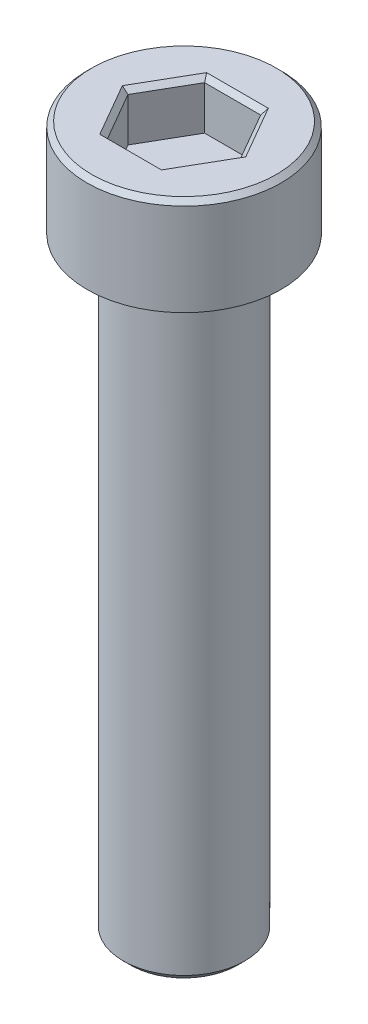
from build123d import *

# Parameters (mm, degrees)
SKETCH_1_R          = 4
EXTRUDE_1_DEPTH     = 4
SKETCH_2_R          = 2.5
EXTRUDE_2_DEPTH     = 25
CUT_EXTRUDE_1_DEPTH = 2
CHAMFER_1_SIZE      = 0.2
CHAMFER_2_SIZE      = 0.3


with BuildPart() as part:
    # 草图1 → 凸台-拉伸1 (new body)
    with BuildSketch(Plane(origin=(0, 0, 0), x_dir=(1, 0, 0), z_dir=(0, 1, 0))):
        Circle(SKETCH_1_R)
    extrude(amount=EXTRUDE_1_DEPTH)

    # 草图2 → 凸台-拉伸2 (add)
    with BuildSketch(Plane.XZ):
        Circle(SKETCH_2_R)
    extrude(amount=EXTRUDE_2_DEPTH)

    # 草图11 → 切除-拉伸1 (cut)
    with BuildSketch(Plane(origin=(0, 4, 0), x_dir=(1, 0, 0), z_dir=(0, 1, 0))):
        Polygon((1.154954177, 1.999853541), (-1.154446882, 2.000146427), (-2.309401058, 0.000292887), (-1.154954177, -1.999853541), (1.154446882, -2.000146427), (2.309401058, -0.000292887), align=None)
    extrude(amount=-CUT_EXTRUDE_1_DEPTH, mode=Mode.SUBTRACT)

    # 倒角1
    chamfer_1_edges = [part.edges().sort_by_distance(p)[0] for p in [
        (1.732177617, 4, -0.999780327),
        (0.000253647, 4, -1.999999984),
        (-1.73192397, 4, -1.000219657),
        (-1.732177617, 4, 0.999780327),
        (-0.000253647, 4, 1.999999984),
        (1.73192397, 4, 1.000219657),
        (-4, 4, 0),
    ]]
    chamfer(chamfer_1_edges, length=CHAMFER_1_SIZE)

    # 倒角2
    chamfer_2_edges = [part.edges().sort_by_distance(p)[0] for p in [
        (-2.5, -25, 0),
    ]]
    chamfer(chamfer_2_edges, length=CHAMFER_2_SIZE)


solid = part.part
